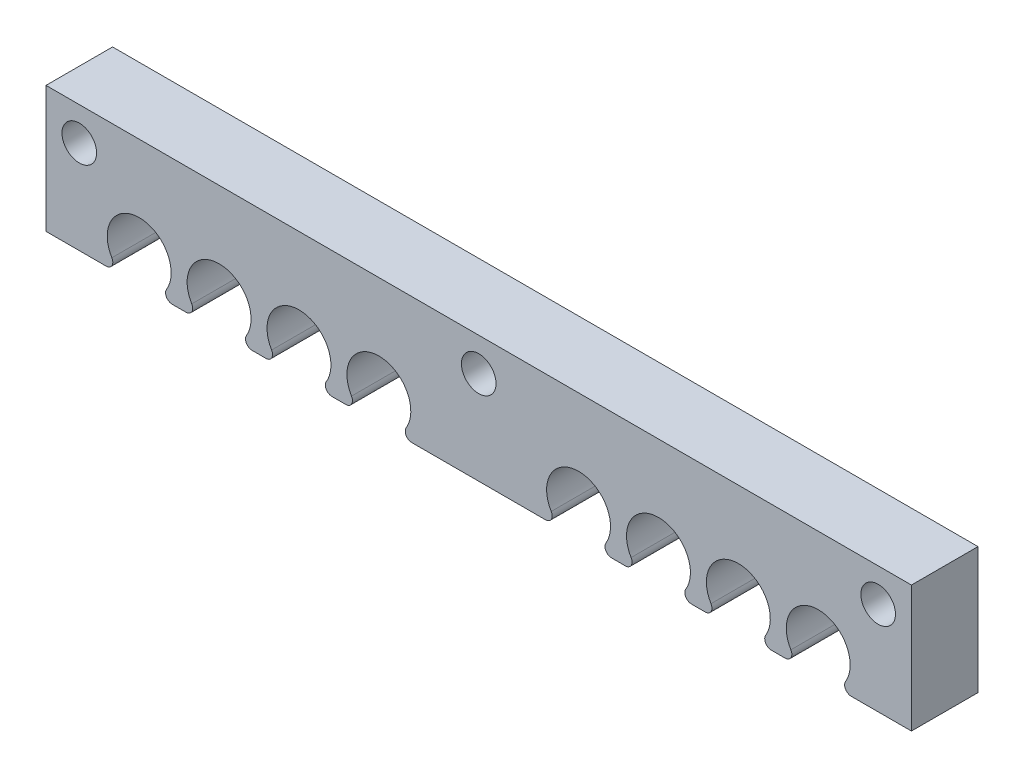
from build123d import *

# Parameters (mm, degrees)
SKETCH1_R           = 2.6
BOSS_EXTRUDE1_DEPTH = 10
SKETCH2_R           = 2.6
CUT_EXTRUDE1_DEPTH  = 8


with BuildPart() as part:
    # Sketch1 → Boss-Extrude1 (new body)
    with BuildSketch(Plane.XY):
        with BuildLine():
            Line((0, 0), (0, 19))
            Line((0, 19), (130, 19))
            Line((130, 19), (130, 0))
            Line((130, 0), (120.963869458, 0))
            ThreePointArc((120.963869458, 0), (120.092881118, 0.508696316), (120.108029897, 1.517241379))
            ThreePointArc((120.108029897, 1.517241379), (116, 8.8), (111.891970103, 1.517241379))
            ThreePointArc((111.891970103, 1.517241379), (111.907118882, 0.508696316), (111.036130542, 0))
            Line((111.036130542, 0), (108.963869458, 0))
            ThreePointArc((108.963869458, 0), (108.092881118, 0.508696316), (108.108029897, 1.517241379))
            ThreePointArc((108.108029897, 1.517241379), (104, 8.8), (99.891970103, 1.517241379))
            ThreePointArc((99.891970103, 1.517241379), (99.907118882, 0.508696316), (99.036130542, 0))
            Line((99.036130542, 0), (96.963869458, 0))
            ThreePointArc((96.963869458, 0), (96.092881118, 0.508696316), (96.108029897, 1.517241379))
            ThreePointArc((96.108029897, 1.517241379), (92, 8.8), (87.891970103, 1.517241379))
            ThreePointArc((87.891970103, 1.517241379), (87.907118882, 0.508696316), (87.036130542, 0))
            Line((87.036130542, 0), (84.963869458, 0))
            ThreePointArc((84.963869458, 0), (84.092881118, 0.508696316), (84.108029897, 1.517241379))
            ThreePointArc((84.108029897, 1.517241379), (80, 8.8), (75.891970103, 1.517241379))
            ThreePointArc((75.891970103, 1.517241379), (75.907118882, 0.508696316), (75.036130542, 0))
            Line((75.036130542, 0), (54.963869458, 0))
            ThreePointArc((54.963869458, 0), (54.092881118, 0.508696316), (54.108029897, 1.517241379))
            ThreePointArc((54.108029897, 1.517241379), (50, 8.8), (45.891970103, 1.517241379))
            ThreePointArc((45.891970103, 1.517241379), (45.907118882, 0.508696316), (45.036130542, 0))
            Line((45.036130542, 0), (42.963869458, 0))
            ThreePointArc((42.963869458, 0), (42.092881118, 0.508696316), (42.108029897, 1.517241379))
            ThreePointArc((42.108029897, 1.517241379), (38, 8.8), (33.891970103, 1.517241379))
            ThreePointArc((33.891970103, 1.517241379), (33.907118882, 0.508696316), (33.036130542, 0))
            Line((33.036130542, 0), (30.963869458, 0))
            ThreePointArc((30.963869458, 0), (30.092881118, 0.508696316), (30.108029897, 1.517241379))
            ThreePointArc((30.108029897, 1.517241379), (26, 8.8), (21.891970103, 1.517241379))
            ThreePointArc((21.891970103, 1.517241379), (21.907118882, 0.508696316), (21.036130542, 0))
            Line((21.036130542, 0), (18.963869458, 0))
            ThreePointArc((18.963869458, 0), (18.092881118, 0.508696316), (18.108029897, 1.517241379))
            ThreePointArc((18.108029897, 1.517241379), (14, 8.8), (9.891970103, 1.517241379))
            ThreePointArc((9.891970103, 1.517241379), (9.907118882, 0.508696316), (9.036130542, 0))
            Line((9.036130542, 0), (0, 0))
        make_face()
        with Locations((5, 14)):
            Circle(SKETCH1_R, mode=Mode.SUBTRACT)
        with Locations((65, 14)):
            Circle(SKETCH1_R, mode=Mode.SUBTRACT)
        with Locations((125, 14)):
            Circle(SKETCH1_R, mode=Mode.SUBTRACT)
    extrude(amount=BOSS_EXTRUDE1_DEPTH)

    # Sketch2 → Cut-Extrude1 (cut)
    with BuildSketch(Plane.XZ):
        with Locations((4.6, 5)):
            Circle(SKETCH2_R)
        with Locations((65, 5)):
            Circle(SKETCH2_R)
        with Locations((125.4, 5)):
            Circle(SKETCH2_R)
    extrude(amount=-CUT_EXTRUDE1_DEPTH, mode=Mode.SUBTRACT)


solid = part.part
